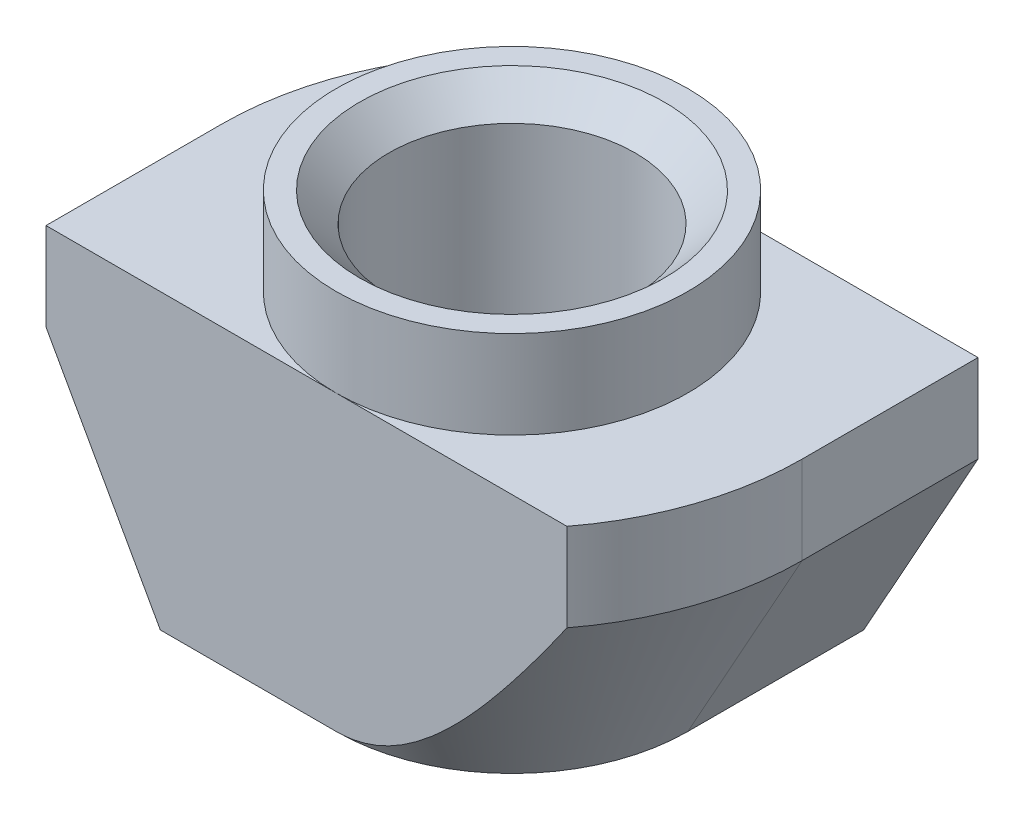
from build123d import *

# Parameters (mm, degrees)
EXTRUDE_1_DEPTH     = 3
SKETCH_4_OUTSIDE_W  = 14.556
SKETCH_4_OUTSIDE_H  = 10.656
SKETCH_4_OUTSIDE_R  = 3
CUT_EXTRUDE_1_DEPTH = 1.5
CUT_EXTRUDE_2_DEPTH = 6


with BuildPart() as part:
    # Эскиз1 → Бобышка-Вытянуть1 (new body, symmetric)
    with BuildSketch(Plane.XY):
        Polygon((3, 0), (-3, 0), (-3, -1.5), (-4.95, -1.5), (-4.95, -6.5), (4.95, -6.5), (4.95, -1.5), (3, -1.5), align=None)
    extrude(amount=EXTRUDE_1_DEPTH, both=True)

    # Эскиз3 → Отверстие обработанное метчиком M51 (revolve, cut)
    with BuildSketch(Plane(origin=(0, 0, 0), x_dir=(0, 0, 1), z_dir=(1, 0, 0))):
        Polygon((0, 0), (0, 6.5), (2.6, 6.5), (2.1, 6), (2.1, 0.5), (2.6, 0), align=None)
    revolve(axis=Axis((0, 6.35, 0), (0, -1, 0)), mode=Mode.SUBTRACT)

    # Эскиз4 outside → Вырез-Вытянуть1 (cut)
    with BuildSketch(Plane(origin=(0, 0, 0), x_dir=(1, 0, 0), z_dir=(0, 1, 0))):
        Rectangle(SKETCH_4_OUTSIDE_W, SKETCH_4_OUTSIDE_H)
        with Locations(Location((0, 0, 0), (0, 0, 270))):  # turned: the seam where the file's is
            Circle(SKETCH_4_OUTSIDE_R, mode=Mode.SUBTRACT)
    extrude(amount=-CUT_EXTRUDE_1_DEPTH, mode=Mode.SUBTRACT)

    # Эскиз5 → Вырез-Вытянуть2 (cut, through all)
    with BuildSketch(Plane(origin=(0, -1.5, 0), x_dir=(1, 0, 0), z_dir=(0, 1, 0))):
        with BuildLine():
            Line((-4.95, 0), (-4.95, 3))
            Line((-4.95, 3), (-3.937321425, 3))
            ThreePointArc((-3.937321425, 3), (-4.690002188, 1.583154912), (-4.95, 0))
        make_face()
        with BuildLine():
            Line((4.95, 0), (4.95, -3))
            Line((4.95, -3), (3.937321425, -3))
            ThreePointArc((3.937321425, -3), (4.690002188, -1.583154912), (4.95, 0))
        make_face()
    extrude(amount=-CUT_EXTRUDE_2_DEPTH, mode=Mode.SUBTRACT)

    # Вырез-По траектории1: sweep along a path in Эскиз7
    with BuildLine(Plane.XZ.offset(6.5)) as sweep_1_path:
        Line((0, 4.95), (-4.95, 4.95))
        Line((-4.95, 4.95), (-4.95, 0))
        ThreePointArc((-4.95, 0), (-3.500178567, -3.500178567), (0, -4.95))
        Line((0, -4.95), (4.95, -4.95))
        Line((4.95, -4.95), (4.95, 0))
        ThreePointArc((4.95, 0), (3.500178567, 3.500178567), (0, 4.95))
    # Эскиз6 → Вырез-По траектории1 (sweep, cut)
    with BuildSketch(Plane.XY.offset(3)):
        Polygon((-4.95, -3), (-4.95, -6.5), (-3, -6.5), align=None)
    sweep(path=sweep_1_path.line, transition=Transition.RIGHT, mode=Mode.SUBTRACT)


solid = part.part
